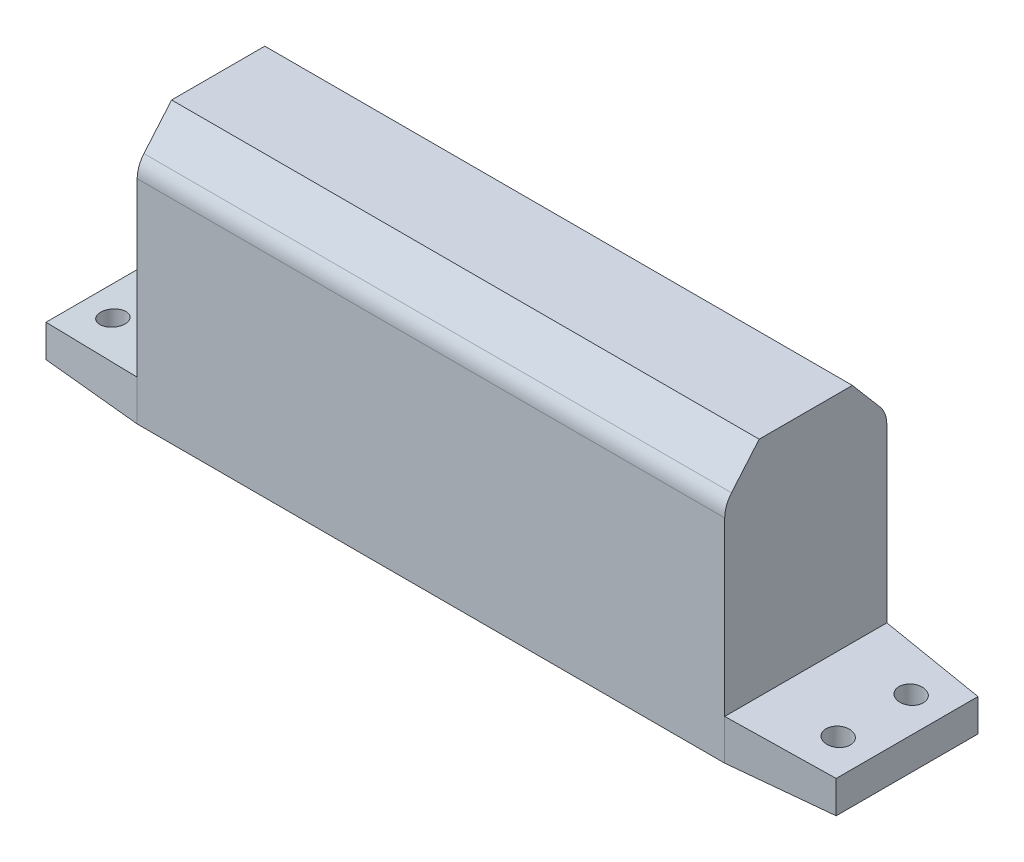
from build123d import *

# Parameters (mm, degrees)
SKETCH1_W           = 195
SKETCH1_H           = 40
BOSS_EXTRUDE1_DEPTH = 10
SKETCH2_W           = 145
SKETCH2_H           = 40
BOSS_EXTRUDE2_DEPTH = 55
CUT_EXTRUDE1_DEPTH  = 237
FILLET1_R           = 7
CUT_EXTRUDE2_DEPTH  = 237
CUT_EXTRUDE3_DEPTH  = 237
SKETCH6_R           = 3
CUT_EXTRUDE4_DEPTH  = 237
SKETCH7_R           = 17.5
BOSS_EXTRUDE3_DEPTH = 2
BOSS_EXTRUDE4_DEPTH = 6
SKETCH9_R           = 4.5
BOSS_EXTRUDE5_DEPTH = 10
BOSS_EXTRUDE7_DEPTH = 5


with BuildPart() as part:
    # Sketch1 → Boss-Extrude1 (new body)
    with BuildSketch(Plane(origin=(0, 0, 0), x_dir=(1, 0, 0), z_dir=(0, 1, 0))):
        Rectangle(SKETCH1_W, SKETCH1_H)
    extrude(amount=BOSS_EXTRUDE1_DEPTH)

    # Sketch2 → Boss-Extrude2 (add)
    with BuildSketch(Plane(origin=(0, 10, 0), x_dir=(1, 0, 0), z_dir=(0, 1, 0))):
        Rectangle(SKETCH2_W, SKETCH2_H)
    extrude(amount=BOSS_EXTRUDE2_DEPTH)

    # Sketch3 → Cut-Extrude1 (cut)
    with BuildSketch(Plane.ZY.offset(72.5)):
        Polygon((-11.5, 65), (-20, 55), (-20, 68.642587118), align=None)
        Polygon((11.5, 65), (20, 55), (20, 68.642587118), align=None)
    extrude(amount=-CUT_EXTRUDE1_DEPTH, mode=Mode.SUBTRACT)

    # Fillet1
    fillet1_edges = [part.edges().sort_by_distance(p)[0] for p in [
        (0, 55, -20),
        (0, 55, 20),
    ]]
    fillet(fillet1_edges, radius=FILLET1_R)

    # Sketch4 → Cut-Extrude2 (cut)
    with BuildSketch(Plane(origin=(0, 0, -20), x_dir=(-1, 0, 0), z_dir=(0, 0, -1))):
        Polygon((72.5, 10), (97.5, 8), (97.5, 10), align=None)
        Polygon((-97.5, 10), (-72.5, 10), (-97.5, 8), align=None)
    extrude(amount=-CUT_EXTRUDE2_DEPTH, mode=Mode.SUBTRACT)

    # Sketch5 → Cut-Extrude3 (cut)
    with BuildSketch(Plane.XZ):
        Polygon((97.5, -20), (97.5, -17.5), (72.5, -20), align=None)
        Polygon((97.5, 20), (72.5, 20), (97.5, 17.5), align=None)
        Polygon((-97.5, 17.5), (-72.5, 20), (-97.5, 20), align=None)
        Polygon((-72.5, -20), (-97.5, -17.5), (-97.5, -20), align=None)
    extrude(amount=-CUT_EXTRUDE3_DEPTH, mode=Mode.SUBTRACT)

    # Sketch6 → Cut-Extrude4 (cut)
    with BuildSketch(Plane.XZ):
        with Locations((89.5, 9)):
            Circle(SKETCH6_R)
        with Locations((89.5, -9)):
            Circle(SKETCH6_R)
        with Locations((-89.5, 9)):
            Circle(SKETCH6_R)
        with Locations((-89.5, -9)):
            Circle(SKETCH6_R)
    extrude(amount=-CUT_EXTRUDE4_DEPTH, mode=Mode.SUBTRACT)

    # Sketch7 → Boss-Extrude3 (add)
    with BuildSketch(Plane(origin=(0, 0, -20), x_dir=(-1, 0, 0), z_dir=(0, 0, -1))):
        with Locations((0, 22.5)):
            Circle(SKETCH7_R)
    extrude(amount=BOSS_EXTRUDE3_DEPTH)

    # Sketch8 → Boss-Extrude4 (add)
    with BuildSketch(Plane(origin=(0, 0, -22), x_dir=(-1, 0, 0), z_dir=(0, 0, -1))):
        Polygon((8.082903769, 8.5), (16.165807537, 22.5), (8.082903769, 36.5), (-8.082903769, 36.5), (-16.165807537, 22.5), (-8.082903769, 8.5), align=None)
    extrude(amount=BOSS_EXTRUDE4_DEPTH)

    # Sketch9 → Boss-Extrude5 (add)
    with BuildSketch(Plane(origin=(0, 0, -28), x_dir=(-1, 0, 0), z_dir=(0, 0, -1))):
        with Locations((0, 22.5)):
            Circle(SKETCH9_R)
    extrude(amount=BOSS_EXTRUDE5_DEPTH)

    # Sketch12 → Boss-Extrude7 (add)
    with BuildSketch(Plane(origin=(0, 0, -38), x_dir=(-1, 0, 0), z_dir=(0, 0, -1))):
        Polygon((2.100473826, 16.281199441), (6.435876178, 21.209663414), (4.335402352, 27.428463972), (-2.100473826, 28.718800559), (-6.435876178, 23.790336586), (-4.335402352, 17.571536028), align=None)
    extrude(amount=BOSS_EXTRUDE7_DEPTH)


solid = part.part
